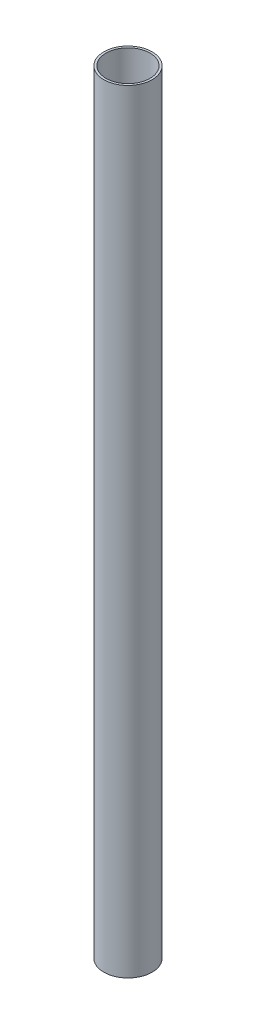
from build123d import *

# Parameters (mm, degrees)
SKETCH1_R           = 7.9375
SKETCH1_R_2         = 7.2263
BOSS_EXTRUDE1_DEPTH = 254


with BuildPart() as part:
    # Sketch1 → Boss-Extrude1 (new body)
    with BuildSketch(Plane(origin=(0, 0, 0), x_dir=(1, 0, 0), z_dir=(0, 1, 0))):
        Circle(SKETCH1_R)
        Circle(SKETCH1_R_2, mode=Mode.SUBTRACT)
    extrude(amount=BOSS_EXTRUDE1_DEPTH)


solid = part.part
